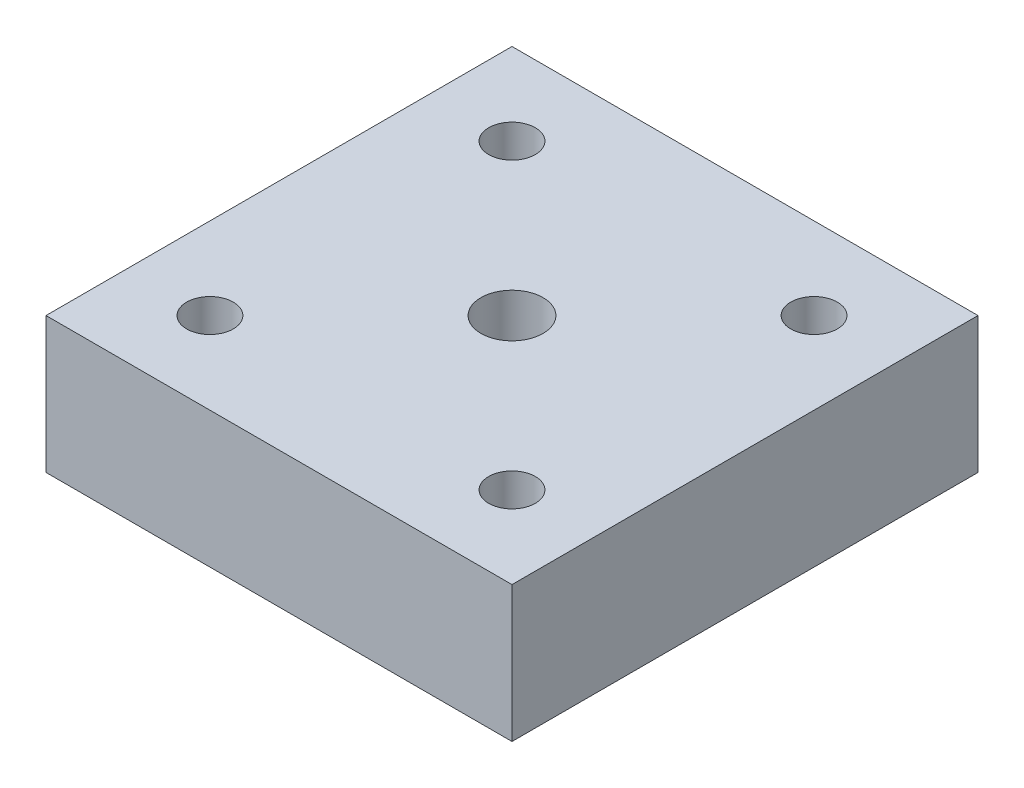
from build123d import *

# Parameters (mm, degrees)
SKETCH1_W           = 120
SKETCH1_H           = 120
SKETCH1_R           = 8
SKETCH1_R_2         = 6
BOSS_EXTRUDE1_DEPTH = 35


with BuildPart() as part:
    # Sketch1 → Boss-Extrude1 (new body)
    with BuildSketch(Plane(origin=(0, 0, 0), x_dir=(1, 0, 0), z_dir=(0, 1, 0))):
        Rectangle(SKETCH1_W, SKETCH1_H)
        Circle(SKETCH1_R, mode=Mode.SUBTRACT)
        with Locations((-38.890872965, -38.890872965)):
            Circle(SKETCH1_R_2, mode=Mode.SUBTRACT)
        with Locations((38.890872965, -38.890872965)):
            Circle(SKETCH1_R_2, mode=Mode.SUBTRACT)
        with Locations((-38.890872965, 38.890872965)):
            Circle(SKETCH1_R_2, mode=Mode.SUBTRACT)
        with Locations((38.890872965, 38.890872965)):
            Circle(SKETCH1_R_2, mode=Mode.SUBTRACT)
    extrude(amount=BOSS_EXTRUDE1_DEPTH)


solid = part.part
